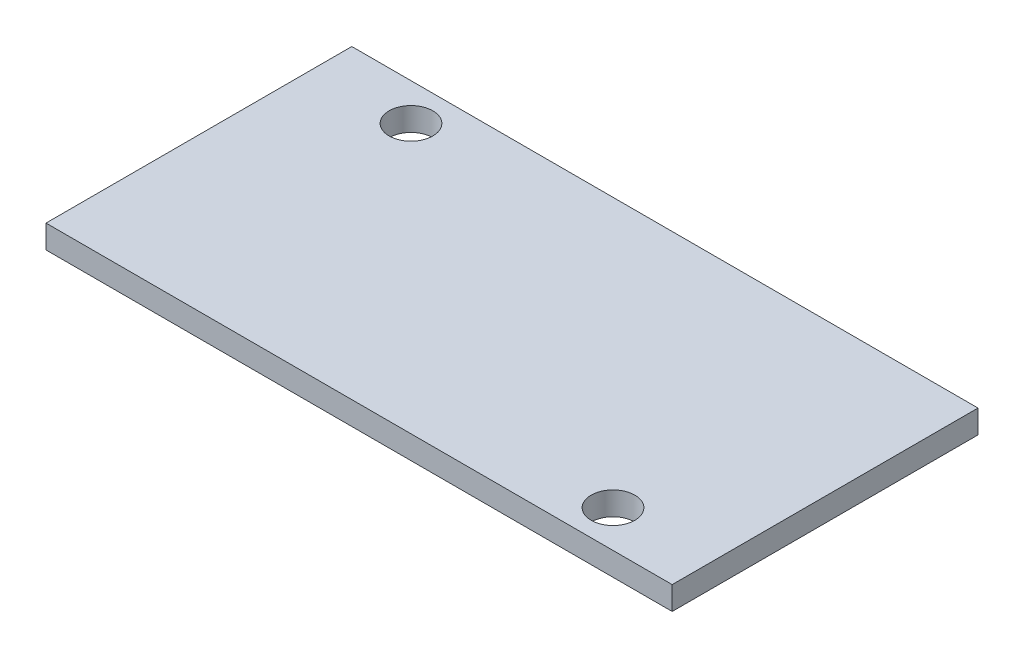
from build123d import *

# Parameters (mm, degrees)
SKETCH1_W           = 43
SKETCH1_H           = 21
SKETCH1_R           = 1.5
BOSS_EXTRUDE3_DEPTH = 1.6


with BuildPart() as part:
    # Sketch1 → Boss-Extrude3 (new body)
    with BuildSketch(Plane(origin=(0, 0, 0), x_dir=(1, 0, 0), z_dir=(0, 1, 0))):
        with Locations((-2.319495713, 10.962358116)):
            Rectangle(SKETCH1_W, SKETCH1_H)
        with Locations((-17.215495713, 18.922358116)):
            Circle(SKETCH1_R, mode=Mode.SUBTRACT)
        with Locations((12.576504287, 3.002358116)):
            Circle(SKETCH1_R, mode=Mode.SUBTRACT)
    extrude(amount=BOSS_EXTRUDE3_DEPTH)


solid = part.part
